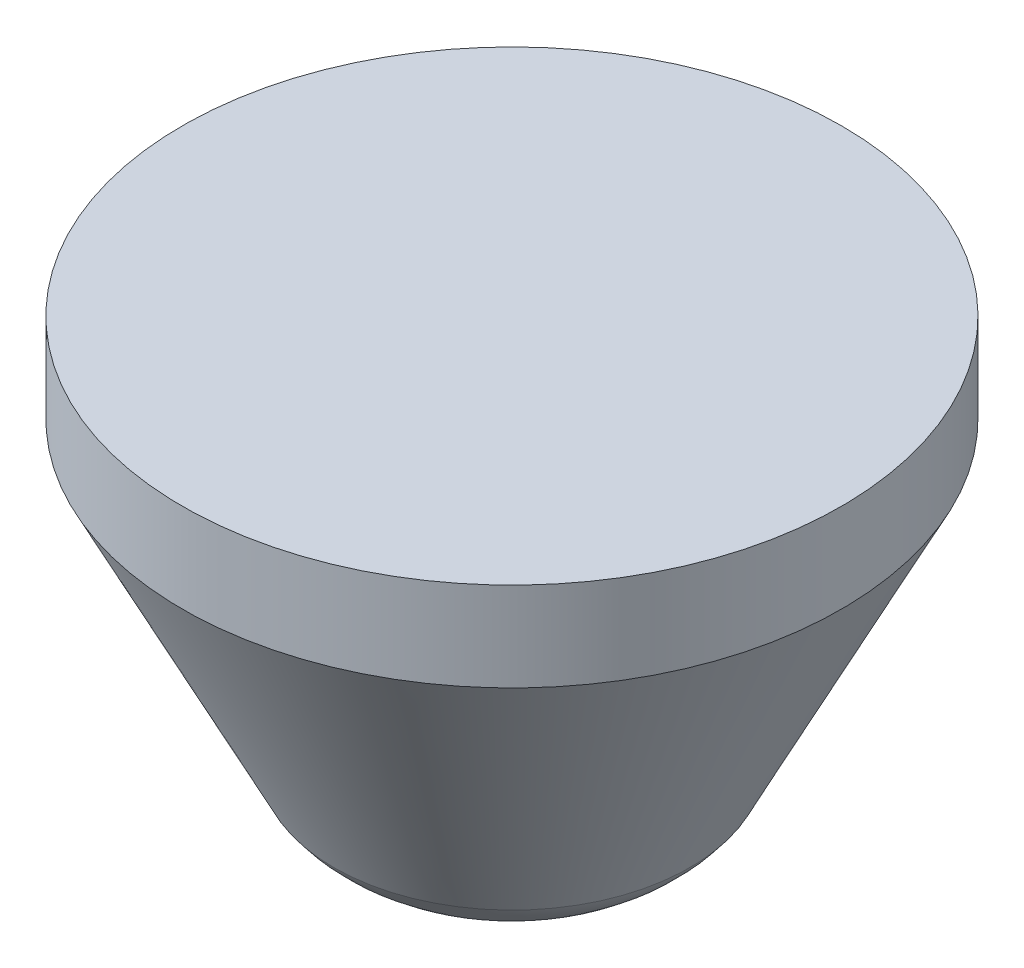
from build123d import *


with BuildPart() as part:
    # Croquis1 → Revolución1 (revolve)
    with BuildSketch(Plane.XY):
        with BuildLine():
            Line((0, 0), (0, 10))
            Line((0, 10), (7.4, 10))
            Line((7.4, 10), (7.4, 8))
            Line((7.4, 8), (3.996590684, 1.273309447))
            ThreePointArc((3.996590684, 1.273309447), (2.925333986, 0.337287881), (1.543319453, 0))
            Line((1.543319453, 0), (0, 0))
        make_face()
    revolve(axis=Axis((0, 0, 0), (0, 1, 0)))


solid = part.part
